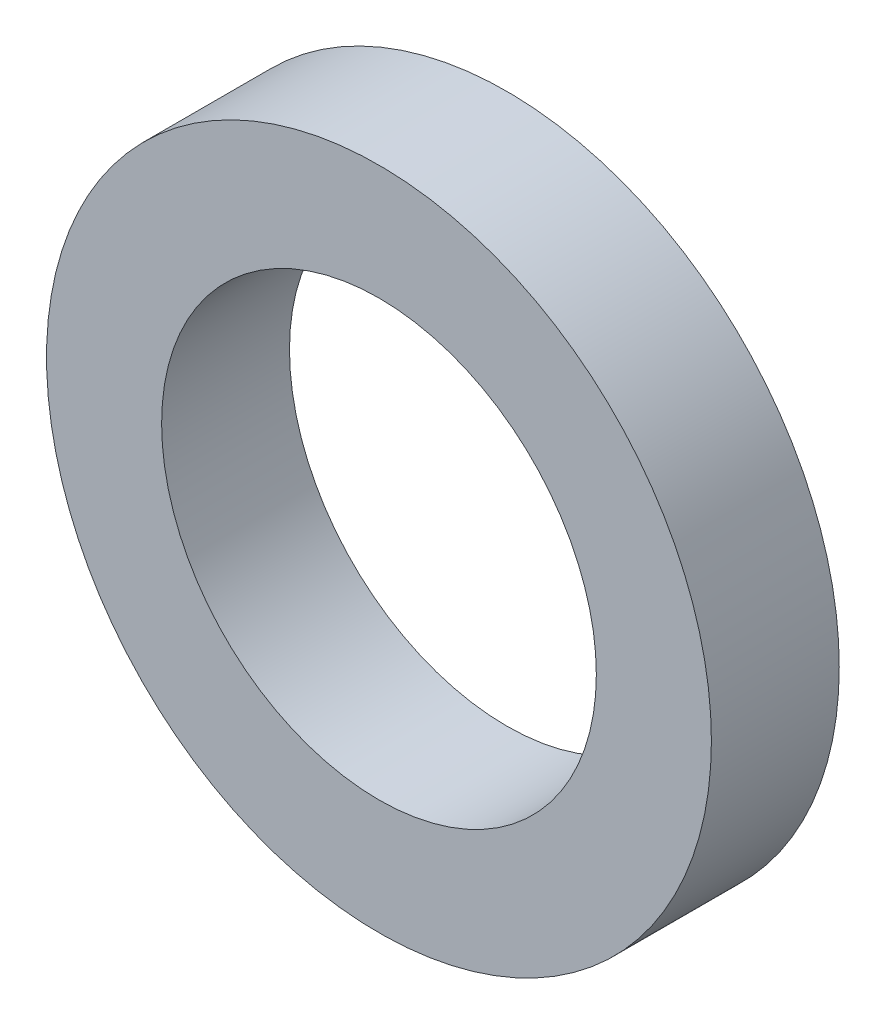
from build123d import *

# Parameters (mm, degrees)
SKETCH1_R           = 13
BOSS_EXTRUDE1_DEPTH = 5
SKETCH2_R           = 8.5
CUT_EXTRUDE1_DEPTH  = 5


with BuildPart() as part:
    # Sketch1 → Boss-Extrude1 (new body)
    with BuildSketch(Plane.XY):
        Circle(SKETCH1_R)
    extrude(amount=BOSS_EXTRUDE1_DEPTH)

    # Sketch2 → Cut-Extrude1 (cut)
    with BuildSketch(Plane.XY.offset(5)):
        Circle(SKETCH2_R)
    extrude(amount=-CUT_EXTRUDE1_DEPTH, mode=Mode.SUBTRACT)


solid = part.part
